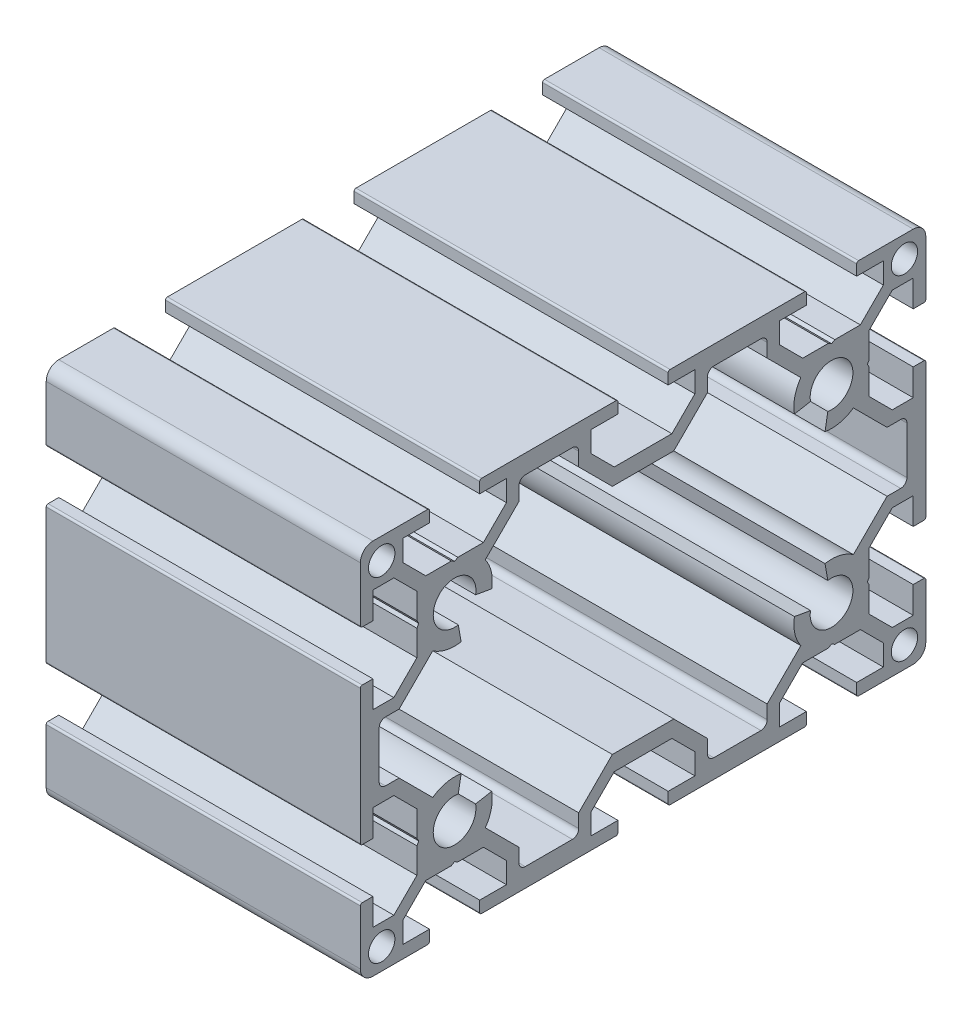
from build123d import *

# Parameters (mm, degrees)
SKETCH11_R               = 2.1
STRUCTURAL_MEMBER1_DEPTH = 50


with BuildPart() as part:
    # Sketch11 → Structural Member1 (new body)
    with BuildSketch(Plane.YZ.offset(-25)):
        with BuildLine():
            Line((-30, 25.7), (-30, 4.3))
            ThreePointArc((-30, 4.3), (-29.912132034, 4.087867966), (-29.7, 4))
            Line((-29.7, 4), (-28, 4))
            Line((-28, 4), (-28, 8.25))
            Line((-28, 8.25), (-24.6642, 8.25))
            Line((-24.6642, 8.25), (-21, 4.5858))
            Line((-21, 4.5858), (-21, -4.5858))
            Line((-21, -4.5858), (-24.6642, -8.25))
            Line((-24.6642, -8.25), (-28, -8.25))
            Line((-28, -8.25), (-28, -4))
            Line((-28, -4), (-29.7, -4))
            ThreePointArc((-29.7, -4), (-29.912132034, -4.087867966), (-30, -4.3))
            Line((-30, -4.3), (-30, -25.7))
            ThreePointArc((-30, -25.7), (-29.912132034, -25.912132034), (-29.7, -26))
            Line((-29.7, -26), (-28, -26))
            Line((-28, -26), (-28, -21.75))
            Line((-28, -21.75), (-24.6642, -21.75))
            Line((-24.6642, -21.75), (-21, -25.4142))
            Line((-21, -25.4142), (-21, -29.480384758))
            Line((-21, -29.480384758), (-20.7, -30))
            Line((-20.7, -30), (-21, -30.519615242))
            Line((-21, -30.519615242), (-21, -34.5858))
            Line((-21, -34.5858), (-24.6642, -38.25))
            Line((-24.6642, -38.25), (-28, -38.25))
            Line((-28, -38.25), (-28, -34))
            Line((-28, -34), (-29.7, -34))
            ThreePointArc((-29.7, -34), (-29.912132034, -34.087867966), (-30, -34.3))
            Line((-30, -34.3), (-30, -43))
            ThreePointArc((-30, -43), (-29.414213562, -44.414213562), (-28, -45))
            Line((-28, -45), (-19.3, -45))
            ThreePointArc((-19.3, -45), (-19.087867966, -44.912132034), (-19, -44.7))
            Line((-19, -44.7), (-19, -43))
            Line((-19, -43), (-23.25, -43))
            Line((-23.25, -43), (-23.25, -39.6642))
            Line((-23.25, -39.6642), (-19.5858, -36))
            Line((-19.5858, -36), (-15.519615242, -36))
            Line((-15.519615242, -36), (-15, -35.7))
            Line((-15, -35.7), (-14.480384758, -36))
            Line((-14.480384758, -36), (-10.4142, -36))
            Line((-10.4142, -36), (-6.75, -39.6642))
            Line((-6.75, -39.6642), (-6.75, -43))
            Line((-6.75, -43), (-11, -43))
            Line((-11, -43), (-11, -44.7))
            ThreePointArc((-11, -44.7), (-10.912132034, -44.912132034), (-10.7, -45))
            Line((-10.7, -45), (10.7, -45))
            ThreePointArc((10.7, -45), (10.912132034, -44.912132034), (11, -44.7))
            Line((11, -44.7), (11, -43))
            Line((11, -43), (6.75, -43))
            Line((6.75, -43), (6.75, -39.6642))
            Line((6.75, -39.6642), (10.4142, -36))
            Line((10.4142, -36), (14.480384758, -36))
            Line((14.480384758, -36), (15, -35.7))
            Line((15, -35.7), (15.519615242, -36))
            Line((15.519615242, -36), (19.5858, -36))
            Line((19.5858, -36), (23.25, -39.6642))
            Line((23.25, -39.6642), (23.25, -43))
            Line((23.25, -43), (19, -43))
            Line((19, -43), (19, -44.7))
            ThreePointArc((19, -44.7), (19.087867966, -44.912132034), (19.3, -45))
            Line((19.3, -45), (28, -45))
            ThreePointArc((28, -45), (29.414213562, -44.414213562), (30, -43))
            Line((30, -43), (30, -34.3))
            ThreePointArc((30, -34.3), (29.912132034, -34.087867966), (29.7, -34))
            Line((29.7, -34), (28, -34))
            Line((28, -34), (28, -38.25))
            Line((28, -38.25), (24.6642, -38.25))
            Line((24.6642, -38.25), (21, -34.5858))
            Line((21, -34.5858), (21, -30.519615242))
            Line((21, -30.519615242), (20.7, -30))
            Line((20.7, -30), (21, -29.480384758))
            Line((21, -29.480384758), (21, -25.4142))
            Line((21, -25.4142), (24.6642, -21.75))
            Line((24.6642, -21.75), (28, -21.75))
            Line((28, -21.75), (28, -26))
            Line((28, -26), (29.7, -26))
            ThreePointArc((29.7, -26), (29.912132034, -25.912132034), (30, -25.7))
            Line((30, -25.7), (30, -4.3))
            ThreePointArc((30, -4.3), (29.912132034, -4.087867966), (29.7, -4))
            Line((29.7, -4), (28, -4))
            Line((28, -4), (28, -8.25))
            Line((28, -8.25), (24.6642, -8.25))
            Line((24.6642, -8.25), (21, -4.5858))
            Line((21, -4.5858), (21, 4.5858))
            Line((21, 4.5858), (24.6642, 8.25))
            Line((24.6642, 8.25), (28, 8.25))
            Line((28, 8.25), (28, 4))
            Line((28, 4), (29.7, 4))
            ThreePointArc((29.7, 4), (29.912132034, 4.087867966), (30, 4.3))
            Line((30, 4.3), (30, 25.7))
            ThreePointArc((30, 25.7), (29.912132034, 25.912132034), (29.7, 26))
            Line((29.7, 26), (28, 26))
            Line((28, 26), (28, 21.75))
            Line((28, 21.75), (24.6642, 21.75))
            Line((24.6642, 21.75), (21, 25.4142))
            Line((21, 25.4142), (21, 29.480384758))
            Line((21, 29.480384758), (20.7, 30))
            Line((20.7, 30), (21, 30.519615242))
            Line((21, 30.519615242), (21, 34.5858))
            Line((21, 34.5858), (24.6642, 38.25))
            Line((24.6642, 38.25), (28, 38.25))
            Line((28, 38.25), (28, 34))
            Line((28, 34), (29.7, 34))
            ThreePointArc((29.7, 34), (29.912132034, 34.087867966), (30, 34.3))
            Line((30, 34.3), (30, 43))
            ThreePointArc((30, 43), (29.414213562, 44.414213562), (28, 45))
            Line((28, 45), (19.3, 45))
            ThreePointArc((19.3, 45), (19.087867966, 44.912132034), (19, 44.7))
            Line((19, 44.7), (19, 43))
            Line((19, 43), (23.25, 43))
            Line((23.25, 43), (23.25, 39.6642))
            Line((23.25, 39.6642), (19.5858, 36))
            Line((19.5858, 36), (15.519615242, 36))
            Line((15.519615242, 36), (15, 35.7))
            Line((15, 35.7), (14.480384758, 36))
            Line((14.480384758, 36), (10.4142, 36))
            Line((10.4142, 36), (6.75, 39.6642))
            Line((6.75, 39.6642), (6.75, 43))
            Line((6.75, 43), (11, 43))
            Line((11, 43), (11, 44.700000004))
            ThreePointArc((11, 44.700000004), (10.912132033, 44.912132036), (10.7, 45))
            Line((10.7, 45), (-10.7, 45))
            ThreePointArc((-10.7, 45), (-10.912132034, 44.912132034), (-11, 44.7))
            Line((-11, 44.7), (-11, 43))
            Line((-11, 43), (-6.75, 43))
            Line((-6.75, 43), (-6.75, 39.6642))
            Line((-6.75, 39.6642), (-10.4142, 36))
            Line((-10.4142, 36), (-14.480384758, 36))
            Line((-14.480384758, 36), (-15, 35.7))
            Line((-15, 35.7), (-15.519615242, 36))
            Line((-15.519615242, 36), (-19.5858, 36))
            Line((-19.5858, 36), (-23.25, 39.6642))
            Line((-23.25, 39.6642), (-23.25, 43))
            Line((-23.25, 43), (-19, 43))
            Line((-19, 43), (-19, 44.7))
            ThreePointArc((-19, 44.7), (-19.087867966, 44.912132034), (-19.3, 45))
            Line((-19.3, 45), (-28, 45))
            ThreePointArc((-28, 45), (-29.414213562, 44.414213562), (-30, 43))
            Line((-30, 43), (-30, 34.3))
            ThreePointArc((-30, 34.3), (-29.912132034, 34.087867966), (-29.7, 34))
            Line((-29.7, 34), (-28, 34))
            Line((-28, 34), (-28, 38.25))
            Line((-28, 38.25), (-24.6642, 38.25))
            Line((-24.6642, 38.25), (-21, 34.5858))
            Line((-21, 34.5858), (-21, 30.519615242))
            Line((-21, 30.519615242), (-20.7, 30))
            Line((-20.7, 30), (-21, 29.480384758))
            Line((-21, 29.480384758), (-21, 25.4142))
            Line((-21, 25.4142), (-24.6642, 21.75))
            Line((-24.6642, 21.75), (-28, 21.75))
            Line((-28, 21.75), (-28, 26))
            Line((-28, 26), (-29.7, 26))
            ThreePointArc((-29.7, 26), (-29.912132034, 25.912132034), (-30, 25.7))
        make_face()
        with Locations((26.6, -41.6)):
            Circle(SKETCH11_R, mode=Mode.SUBTRACT)
        with Locations((26.6, 41.6)):
            Circle(SKETCH11_R, mode=Mode.SUBTRACT)
        with Locations((-26.6, -41.6)):
            Circle(SKETCH11_R, mode=Mode.SUBTRACT)
        with Locations((-26.6, 41.6)):
            Circle(SKETCH11_R, mode=Mode.SUBTRACT)
        with BuildLine():
            Line((-27, 18.75), (-27, 11.25))
            ThreePointArc((-27, 11.25), (-26.707106781, 10.542893219), (-26, 10.25))
            Line((-26, 10.25), (-23.835772875, 10.25))
            Line((-23.835772875, 10.25), (-18.476185424, 4.890412549))
            Line((-18.476185424, 4.890412549), (-18.476185424, -4.890412549))
            Line((-18.476185424, -4.890412549), (-23.835772875, -10.25))
            Line((-23.835772875, -10.25), (-26, -10.25))
            ThreePointArc((-26, -10.25), (-26.707106781, -10.542893219), (-27, -11.25))
            Line((-27, -11.25), (-27, -18.75))
            ThreePointArc((-27, -18.75), (-26.707106781, -19.457106781), (-26, -19.75))
            Line((-26, -19.75), (-23.835772875, -19.75))
            Line((-23.835772875, -19.75), (-18.476185424, -25.109587451))
            ThreePointArc((-18.476185424, -25.109587451), (-16.319375469, -24.146859956), (-13.958110934, -24.091153482))
            Line((-13.958110934, -24.091153482), (-14.409596196, -26.65165364))
            ThreePointArc((-14.409596196, -26.65165364), (-17.404163056, -32.404163056), (-11.65165364, -29.409596196))
            Line((-11.65165364, -29.409596196), (-9.091153482, -28.958110934))
            ThreePointArc((-9.091153482, -28.958110934), (-9.146859956, -31.319375469), (-10.109587451, -33.476185424))
            Line((-10.109587451, -33.476185424), (-4.75, -38.835772875))
            Line((-4.75, -38.835772875), (-4.75, -41))
            ThreePointArc((-4.75, -41), (-4.457106781, -41.707106781), (-3.75, -42))
            Line((-3.75, -42), (3.75, -42))
            ThreePointArc((3.75, -42), (4.457106781, -41.707106781), (4.75, -41))
            Line((4.75, -41), (4.75, -38.835772875))
            Line((4.75, -38.835772875), (10.109587451, -33.476185424))
            ThreePointArc((10.109587451, -33.476185424), (9.146859956, -31.319375469), (9.091153482, -28.958110934))
            Line((9.091153482, -28.958110934), (11.65165364, -29.409596196))
            ThreePointArc((11.65165364, -29.409596196), (17.404163056, -32.404163056), (14.409596196, -26.65165364))
            Line((14.409596196, -26.65165364), (13.958110934, -24.091153482))
            ThreePointArc((13.958110934, -24.091153482), (16.319375469, -24.146859956), (18.476185424, -25.109587451))
            Line((18.476185424, -25.109587451), (23.835772875, -19.75))
            Line((23.835772875, -19.75), (26, -19.75))
            ThreePointArc((26, -19.75), (26.707106781, -19.457106781), (27, -18.75))
            Line((27, -18.75), (27, -11.25))
            ThreePointArc((27, -11.25), (26.707106781, -10.542893219), (26, -10.25))
            Line((26, -10.25), (23.835772875, -10.25))
            Line((23.835772875, -10.25), (18.476185424, -4.890412549))
            Line((18.476185424, -4.890412549), (18.476185424, 4.890412549))
            Line((18.476185424, 4.890412549), (23.835772875, 10.25))
            Line((23.835772875, 10.25), (26, 10.25))
            ThreePointArc((26, 10.25), (26.707106781, 10.542893219), (27, 11.25))
            Line((27, 11.25), (27, 18.75))
            ThreePointArc((27, 18.75), (26.707106781, 19.457106781), (26, 19.75))
            Line((26, 19.75), (23.835772875, 19.75))
            Line((23.835772875, 19.75), (18.476185424, 25.109587451))
            ThreePointArc((18.476185424, 25.109587451), (16.319375469, 24.146859956), (13.958110934, 24.091153482))
            Line((13.958110934, 24.091153482), (14.409596196, 26.65165364))
            ThreePointArc((14.409596196, 26.65165364), (17.404163056, 32.404163056), (11.65165364, 29.409596196))
            Line((11.65165364, 29.409596196), (9.091153482, 28.958110934))
            ThreePointArc((9.091153482, 28.958110934), (9.146859956, 31.319375469), (10.109587451, 33.476185424))
            Line((10.109587451, 33.476185424), (4.75, 38.835772875))
            Line((4.75, 38.835772875), (4.75, 41))
            ThreePointArc((4.75, 41), (4.457106781, 41.707106781), (3.75, 42))
            Line((3.75, 42), (-3.75, 42))
            ThreePointArc((-3.75, 42), (-4.457106781, 41.707106781), (-4.75, 41))
            Line((-4.75, 41), (-4.75, 38.835772875))
            Line((-4.75, 38.835772875), (-10.109587451, 33.476185424))
            ThreePointArc((-10.109587451, 33.476185424), (-9.146859956, 31.319375469), (-9.091153482, 28.958110934))
            Line((-9.091153482, 28.958110934), (-11.65165364, 29.409596196))
            ThreePointArc((-11.65165364, 29.409596196), (-17.404163056, 32.404163056), (-14.409596196, 26.65165364))
            Line((-14.409596196, 26.65165364), (-13.958110934, 24.091153482))
            ThreePointArc((-13.958110934, 24.091153482), (-16.319375469, 24.146859956), (-18.476185424, 25.109587451))
            Line((-18.476185424, 25.109587451), (-23.835772875, 19.75))
            Line((-23.835772875, 19.75), (-26, 19.75))
            ThreePointArc((-26, 19.75), (-26.707106781, 19.457106781), (-27, 18.75))
        make_face(mode=Mode.SUBTRACT)
    extrude(amount=STRUCTURAL_MEMBER1_DEPTH)


solid = part.part
